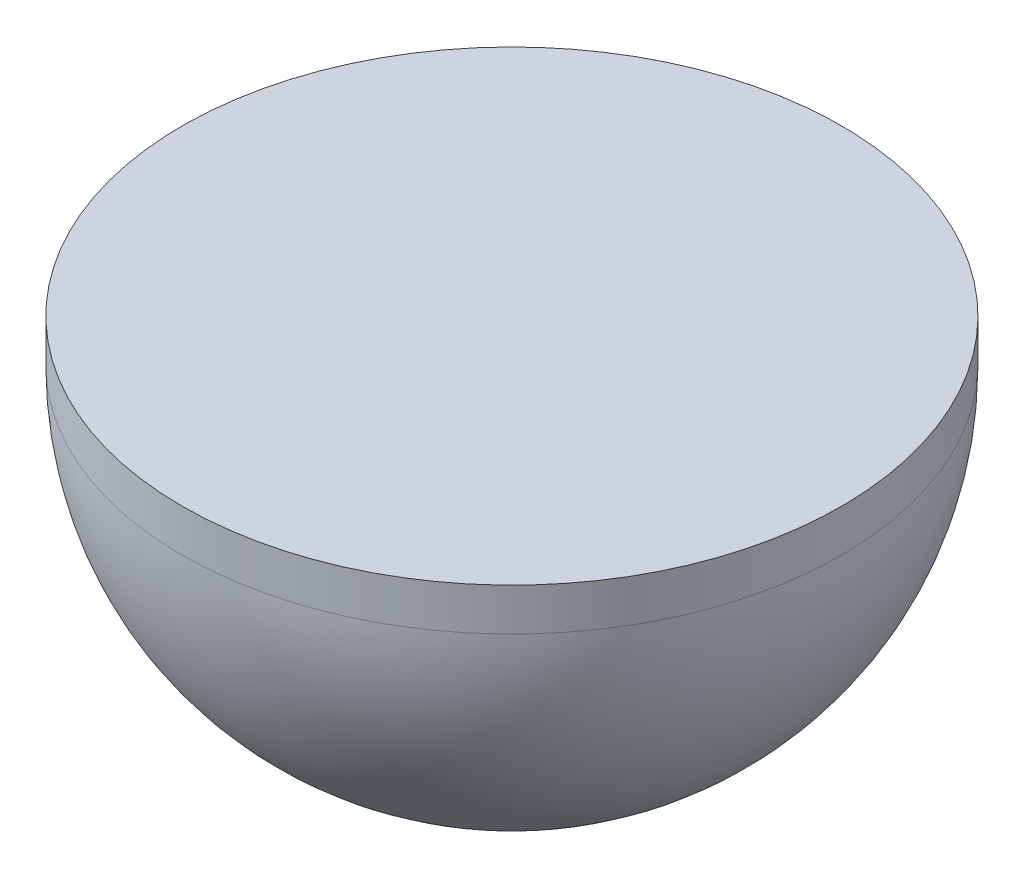
from build123d import *


with BuildPart() as part:
    # Sketch4 → Revolve1 (revolve)
    with BuildSketch(Plane.XY):
        with BuildLine():
            Line((0, 0), (0, 9))
            Line((0, 9), (-70, 9))
            Line((-70, 9), (-70, 0))
            ThreePointArc((-70, 0), (-49.497474683, -49.497474683), (0, -70))
            Line((0, -70), (0, 0))
        make_face()
    revolve(axis=Axis((0, 31.69776157, 0), (0, -1, 0)))


solid = part.part
